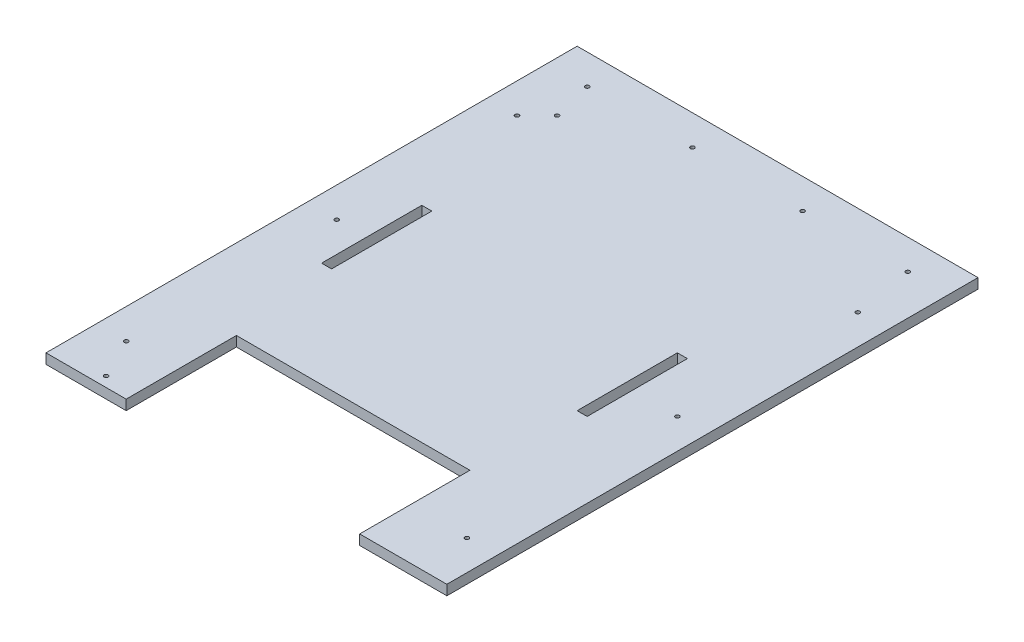
from build123d import *

# Parameters (mm, degrees)
SKETCH1_R           = 2
SKETCH1_W           = 10
SKETCH1_H           = 100
BOSS_EXTRUDE1_DEPTH = 10


with BuildPart() as part:
    # Sketch1 → Boss-Extrude1 (new body)
    with BuildSketch(Plane(origin=(0, 0, 0), x_dir=(1, 0, 0), z_dir=(0, 1, 0))):
        Polygon((-200, 530), (-200, 0), (-120, 0), (-120, 110), (113, 110), (113, 0), (200, 0), (200, 530), align=None)
        with Locations((-160, 500)):
            Circle(SKETCH1_R, mode=Mode.SUBTRACT)
        with Locations((-55, 500)):
            Circle(SKETCH1_R, mode=Mode.SUBTRACT)
        with Locations((55, 500)):
            Circle(SKETCH1_R, mode=Mode.SUBTRACT)
        with Locations((160, 500)):
            Circle(SKETCH1_R, mode=Mode.SUBTRACT)
        with Locations((-170, 50)):
            Circle(SKETCH1_R, mode=Mode.SUBTRACT)
        with Locations((-170, 260)):
            Circle(SKETCH1_R, mode=Mode.SUBTRACT)
        with Locations((-170, 440)):
            Circle(SKETCH1_R, mode=Mode.SUBTRACT)
        with Locations((170, 440)):
            Circle(SKETCH1_R, mode=Mode.SUBTRACT)
        with Locations((170, 260)):
            Circle(SKETCH1_R, mode=Mode.SUBTRACT)
        with Locations((170, 50)):
            Circle(SKETCH1_R, mode=Mode.SUBTRACT)
        with Locations((-150, 10)):
            Circle(SKETCH1_R, mode=Mode.SUBTRACT)
        with Locations((-150, 460)):
            Circle(SKETCH1_R, mode=Mode.SUBTRACT)
        with Locations((-135, 265)):
            Rectangle(SKETCH1_W, SKETCH1_H, mode=Mode.SUBTRACT)
        with Locations((120, 265)):
            Rectangle(SKETCH1_W, SKETCH1_H, mode=Mode.SUBTRACT)
    extrude(amount=BOSS_EXTRUDE1_DEPTH)


solid = part.part
